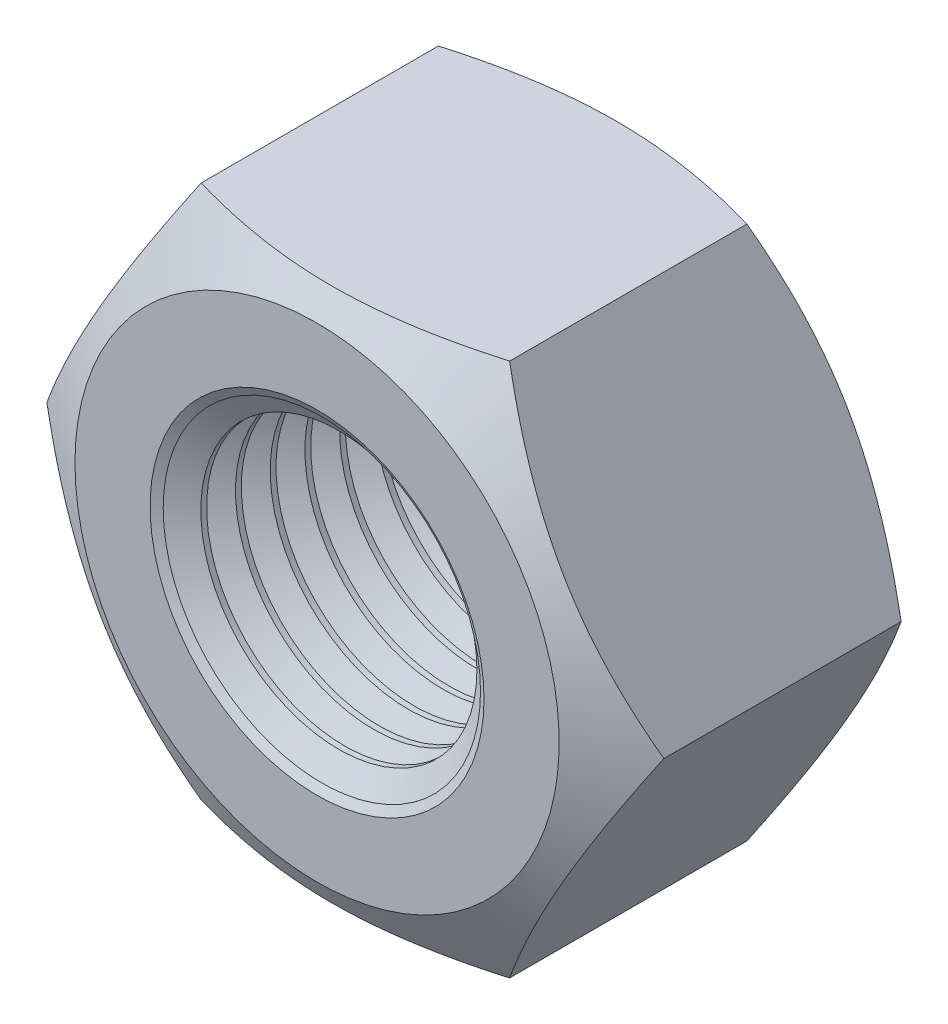
from build123d import *

# Parameters (mm, degrees)
SKETCH1_R               = 2.067
BASENUT_DEPTH           = 4.7
ENDCHAMFER_SIZE         = 0.433
ENDCHAMFER_SIZE2        = 0.249992667
ENDCHAMFER_PART_2_SIZE  = 0.433
ENDCHAMFER_PART_2_SIZE2 = 0.249992667
LPATTERN10_COUNT        = 9
LPATTERN10_PITCH        = 0.5196


with BuildPart() as part:
    # Sketch1 → BaseNut (new body)
    with BuildSketch(Plane.XY):
        Polygon((4.618802154, 0), (2.309401077, 4), (-2.309401077, 4), (-4.618802154, 0), (-2.309401077, -4), (2.309401077, -4), align=None)
        Circle(SKETCH1_R, mode=Mode.SUBTRACT)
    extrude(amount=-BASENUT_DEPTH)

    # Sketch2 → Double-Chamfer (revolve, cut)
    with BuildSketch(Plane(origin=(0, 0, 0), x_dir=(1, 0, 0), z_dir=(0, 1, 0))):
        Polygon((-4.618802154, 4.7), (-3.625, 4.7), (-4.618802154, 4.126228059), align=None)
        Polygon((-4.618802154, 0.573771941), (-4.618802154, 0), (-3.625, 0), align=None)
    revolve(axis=Axis((0, 0, -3.375940562), (0, 0, 1)), mode=Mode.SUBTRACT)

    # EndChamfer
    endchamfer_edges = [part.edges().sort_by_distance(p)[0] for p in [
        (-2.067, 0, -4.7),
    ]]
    endchamfer_side = [part.faces().sort_by_distance(p)[0] for p in [
        (-2.067, 0, -2.35),
    ]]
    chamfer(endchamfer_edges, length=ENDCHAMFER_SIZE, length2=ENDCHAMFER_SIZE2, reference=endchamfer_side[0])

    # EndChamfer part 2
    endchamfer_part_2_edges = [part.edges().sort_by_distance(p)[0] for p in [
        (-2.067, 0, 0),
    ]]
    endchamfer_part_2_side = [part.faces().sort_by_distance(p)[0] for p in [
        (3.522469517, 0, 0),
    ]]
    chamfer(endchamfer_part_2_edges, length=ENDCHAMFER_PART_2_SIZE, length2=ENDCHAMFER_PART_2_SIZE2, reference=endchamfer_part_2_side[0])

    # Sketch3 → Cut-Revolve10 (revolve, cut)
    with BuildSketch(Plane(origin=(0, 0, 0), x_dir=(1, 0, 0), z_dir=(0, 1, 0))):
        Polygon((-2.441989, 4.267), (-2.067, 4.0505), (-1.634, 4.0505), (-1.634, 4.4835), (-2.067, 4.4835), align=None)
    cut_revolve10 = revolve(axis=Axis((0, 0, -7.438254559), (0, 0, -1)), mode=Mode.SUBTRACT)

    # LPattern10: Cut-Revolve10 ×9
    with Locations(*[(0, 0, i * LPATTERN10_PITCH) for i in range(1, LPATTERN10_COUNT)]):
        add(cut_revolve10, mode=Mode.SUBTRACT)


solid = part.part
